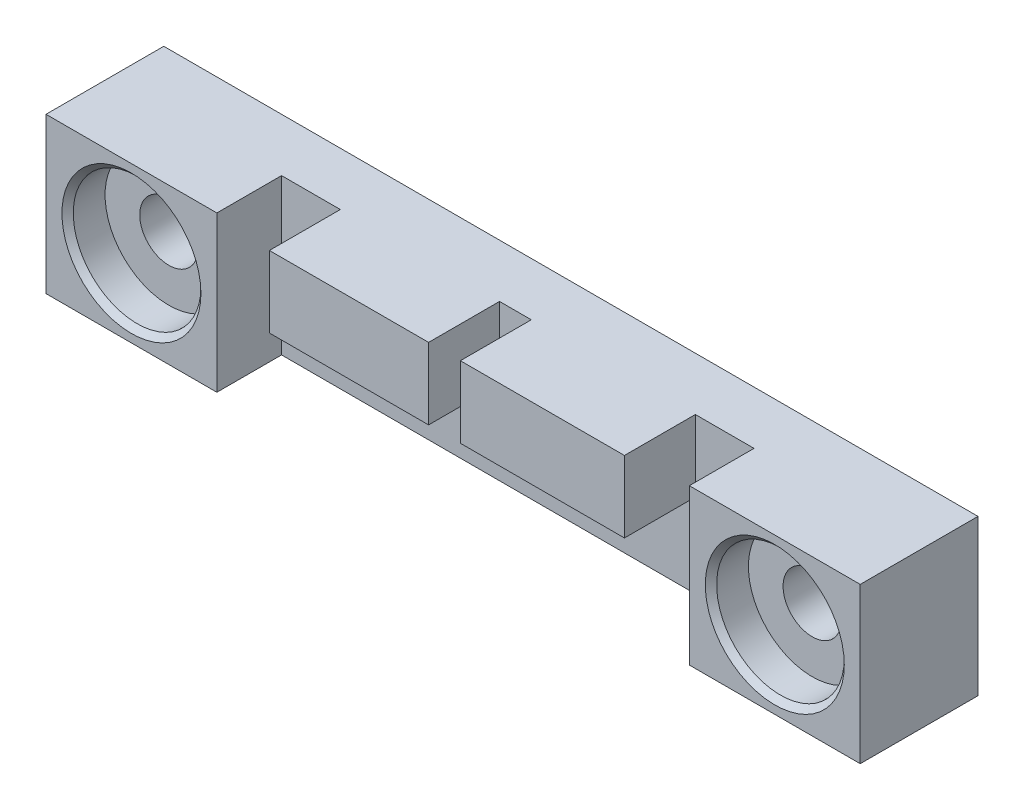
from build123d import *

# Parameters (mm, degrees)
SKETCH1_W                                    = 91.1352
SKETCH1_H                                    = 17.3863
BOSS_EXTRUDE1_DEPTH                          = 13.1826
SKETCH2_W                                    = 52.8828
SKETCH2_H                                    = 17.3863
CUT_EXTRUDE1_DEPTH                           = 7.239
CBORE_FOR_1_4_BINDING_HEAD_MACHINE_S_2_COUNT = 2
CBORE_FOR_1_4_BINDING_HEAD_MACHINE_S_2_PITCH = 72.009
SKETCH7_W                                    = 17.8181
SKETCH7_H                                    = 8.001
SKETCH7_W_2                                  = 18.3642
BOSS_EXTRUDE2_DEPTH                          = 7.9375


with BuildPart() as part:
    # Sketch1 → Boss-Extrude1 (new body)
    with BuildSketch(Plane.XY):
        with Locations((-45.5676, 8.69315)):
            Rectangle(SKETCH1_W, SKETCH1_H)
    extrude(amount=BOSS_EXTRUDE1_DEPTH)

    # Sketch2 → Cut-Extrude1 (cut)
    with BuildSketch(Plane.XY.offset(13.1826)):
        with Locations((-45.5676, 8.69315)):
            Rectangle(SKETCH2_W, SKETCH2_H)
    extrude(amount=-CUT_EXTRUDE1_DEPTH, mode=Mode.SUBTRACT)

    # Sketch6 → CBORE for 1/4 Binding Head Machine Screw1 (revolve, cut)
    with BuildSketch(Plane(origin=(-81.5721, 8.69315, 13.1826), x_dir=(0, -1, 0), z_dir=(1, 0, 0))):
        Polygon((0, 0), (0, 13.1826), (3.2639, 13.1826), (3.2639, 4.191), (7.14375, 4.191), (7.14375, 0.635), (7.77875, 0), align=None)
    cbore_for_1_4_binding_head_machine_screw = revolve(axis=Axis((-81.5721, 8.69315, 19.5326), (0, 0, -1)), mode=Mode.SUBTRACT)

    # CBORE for 1_4 Binding Head Machine S 2: CBORE for 1/4 Binding Head Machine Screw1 ×2
    with Locations(*[(i * CBORE_FOR_1_4_BINDING_HEAD_MACHINE_S_2_PITCH, 0, 0) for i in range(1, CBORE_FOR_1_4_BINDING_HEAD_MACHINE_S_2_COUNT)]):
        add(cbore_for_1_4_binding_head_machine_screw, mode=Mode.SUBTRACT)

    # Sketch7 → Boss-Extrude2 (add)
    with BuildSketch(Plane.XY.offset(5.9436)):
        with Locations((-56.52135, 13.3858)):
            Rectangle(SKETCH7_W, SKETCH7_H)
        with Locations((-34.8742, 13.3858)):
            Rectangle(SKETCH7_W_2, SKETCH7_H)
    extrude(amount=BOSS_EXTRUDE2_DEPTH)


solid = part.part
